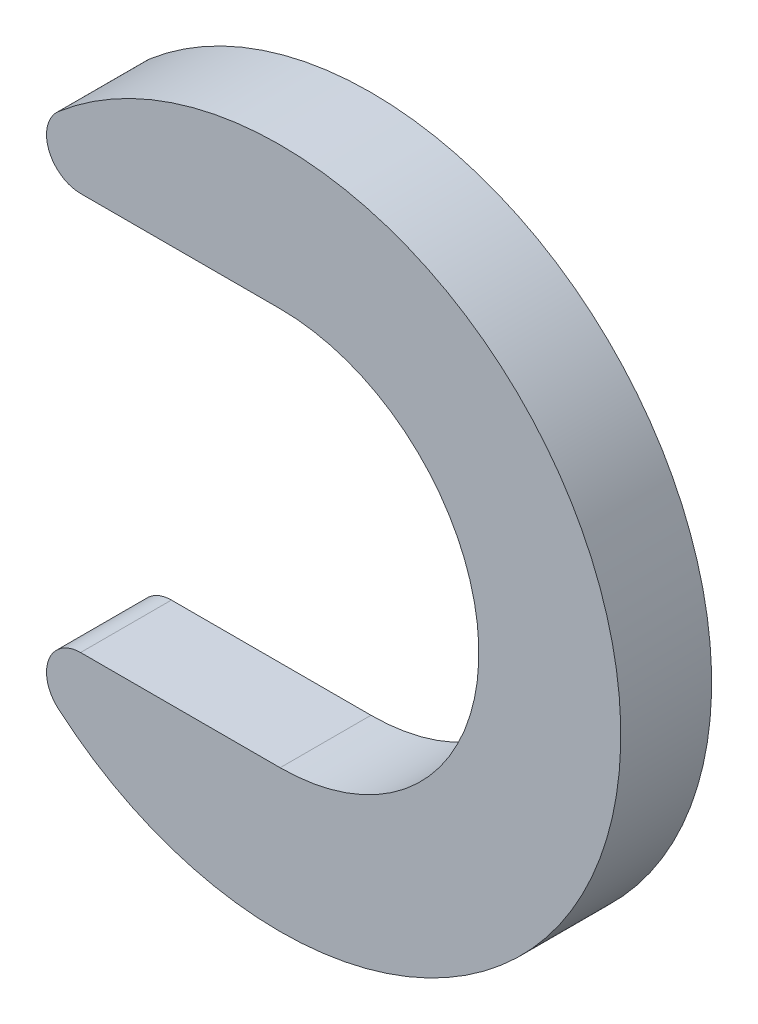
from build123d import *

# Parameters (mm, degrees)
BASE_EXTRUDE_DEPTH = 8


with BuildPart() as part:
    # Sketch1 → Base-Extrude (new body)
    with BuildSketch(Plane.XY):
        with BuildLine():
            Line((-17.571283391, -17.5), (0, -17.5))
            ThreePointArc((0, -17.5), (17.5, 0), (0, 17.5))
            Line((0, 17.5), (-17.571283391, 17.5))
            ThreePointArc((-17.571283391, 17.5), (-20.38494056, 19.459167), (-19.523648212, 22.777777778))
            ThreePointArc((-19.523648212, 22.777777778), (30, 0), (-19.523648212, -22.777777778))
            ThreePointArc((-19.523648212, -22.777777778), (-20.38494056, -19.459167), (-17.571283391, -17.5))
        make_face()
    extrude(amount=BASE_EXTRUDE_DEPTH)


solid = part.part
